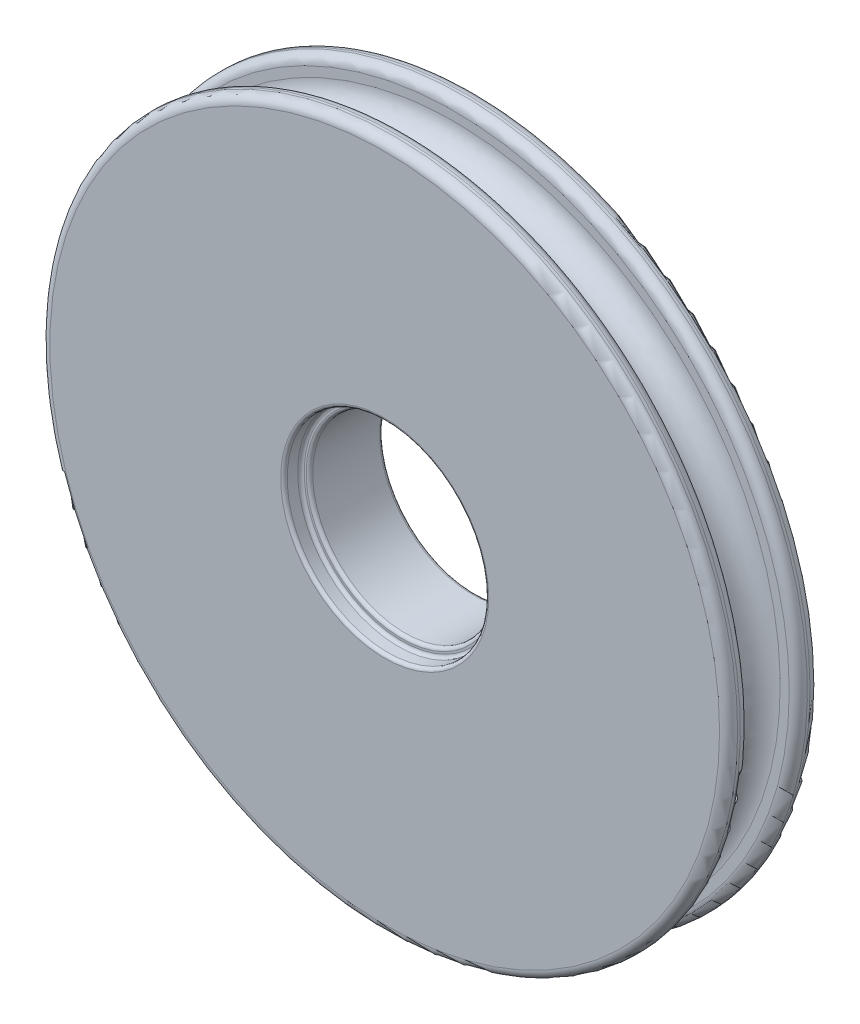
from build123d import *

# Parameters (mm, degrees)
SKETCH1_R           = 24.13
BOSS_EXTRUDE1_DEPTH = 3.175
SKETCH3_R           = 4.7625
CUT_EXTRUDE1_DEPTH  = 1.5875
SKETCH4_R           = 6.477
CUT_EXTRUDE2_DEPTH  = 35.710752095
SKETCH5_R           = 7.0723125
CUT_EXTRUDE3_DEPTH  = 1.190625
FILLET2_R           = 0.2286
FILLET3_R           = 0.635


with BuildPart() as part:
    # Sketch1 → Boss-Extrude1 (new, symmetric)
    with BuildSketch(Plane.XY):
        Circle(SKETCH1_R)
    extrude(amount=BOSS_EXTRUDE1_DEPTH, both=True)

    # Cut-Sweep1: sweep along a path in Sketch6
    with BuildLine(Plane(origin=(0, 0, 0), x_dir=(-1, 0, 0), z_dir=(0, 0, -1))) as cut_sweep1_path:
        CenterArc((0, 0), 22.86, 0, 360)
    # 3DSketch1 → Cut-Sweep1 (sweep, cut)
    with BuildSketch(Plane(origin=(-4.645893567, -22.382923691, -1.7145), x_dir=(0, -0.6946881757557662, 0.7193110165047701), z_dir=(-1, 0, 0))):
        with BuildLine():
            Line((0, 0), (2.300544228, -2.382085755))
            Line((2.300544228, -2.382085755), (4.767061704, 0))
            Line((4.767061704, 0), (2.466517476, 2.382085755))
            ThreePointArc((2.466517476, 2.382085755), (0.04221586, 2.424301615), (0, 0))
        make_face()
    sweep(path=cut_sweep1_path.line, mode=Mode.SUBTRACT)

    # Sketch3 → Cut-Extrude1 (cut, symmetric)
    with BuildSketch(Plane.XY):
        Circle(SKETCH3_R)
    extrude(amount=CUT_EXTRUDE1_DEPTH, both=True, mode=Mode.SUBTRACT)

    # Sketch4 → Cut-Extrude2 (cut, through all)
    with BuildSketch(Plane.XY.offset(3.175)):
        Circle(SKETCH4_R)
    extrude(amount=-CUT_EXTRUDE2_DEPTH, mode=Mode.SUBTRACT)

    # Sketch5 → Cut-Extrude3 (cut)
    with BuildSketch(Plane.XY.offset(3.175)):
        Circle(SKETCH5_R)
    extrude(amount=-CUT_EXTRUDE3_DEPTH, mode=Mode.SUBTRACT)

    # Fillet2
    fillet2_edges = [part.edges().sort_by_distance(p)[0] for p in [
        (-6.477, 0, -3.175),
        (-7.0723125, 0, 3.175),
        (-7.0723125, 0, 1.984375),
        (-6.477, 0, 1.984375),
    ]]
    fillet(fillet2_edges, radius=FILLET2_R)

    # Fillet3
    fillet3_edges = [part.edges().sort_by_distance(p)[0] for p in [
        (-24.13, 0, -3.175),
        (-24.13, 0, 3.175),
        (0.131656124, -24.129640831, 1.7145),
        (-0.131656125, 24.129640831, -1.7145),
    ]]
    fillet(fillet3_edges, radius=FILLET3_R)


solid = part.part
